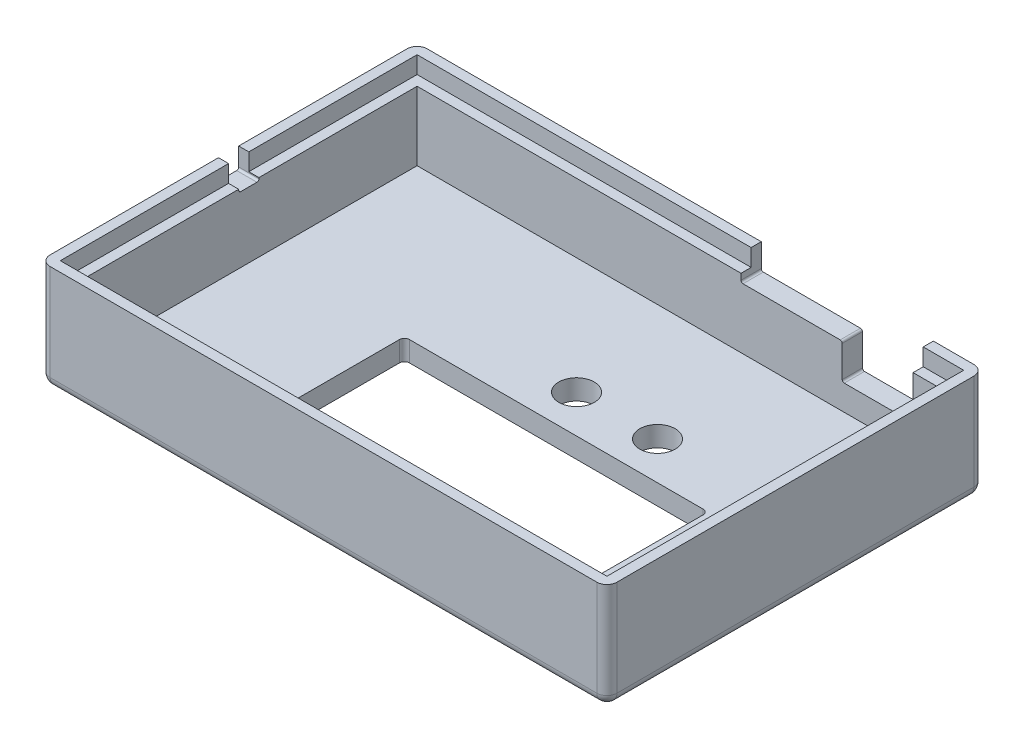
from build123d import *

# Parameters (mm, degrees)
SKETCH1_W           = 56
SKETCH1_H           = 37.25
BOSS_EXTRUDE1_DEPTH = 2
SKETCH2_W           = 56
SKETCH2_H           = 37.25
SKETCH2_W_2         = 52
SKETCH2_H_2         = 33.25
BOSS_EXTRUDE2_DEPTH = 8.5
SKETCH5_W           = 54
SKETCH5_H           = 35.25
SKETCH5_W_2         = 52
SKETCH5_H_2         = 33.25
CUT_EXTRUDE1_DEPTH  = 1
FILLET1_R           = 1
SKETCH7_W           = 30
SKETCH7_H           = 14
CUT_EXTRUDE3_DEPTH  = 10
SKETCH8_R           = 1.75
CUT_EXTRUDE4_DEPTH  = 10
SKETCH9_W           = 7
SKETCH9_H           = 6
CUT_EXTRUDE5_DEPTH  = 3
SKETCH10_W          = 10
SKETCH10_H          = 2.5
CUT_EXTRUDE6_DEPTH  = 3
FILLET2_R           = 0.5
FILLET3_R           = 1
FILLET5_R           = 0.2
CUT_EXTRUDE8_DEPTH  = 0.7
CUT_EXTRUDE10_DEPTH = 5
FILLET6_R           = 0.2


with BuildPart() as part:
    # Sketch1 → Boss-Extrude1 (new body)
    with BuildSketch(Plane(origin=(0, 0, 0), x_dir=(1, 0, 0), z_dir=(0, 1, 0))):
        with Locations((28, 18.625)):
            Rectangle(SKETCH1_W, SKETCH1_H)
    extrude(amount=BOSS_EXTRUDE1_DEPTH)

    # Sketch2 → Boss-Extrude2 (add)
    with BuildSketch(Plane(origin=(0, 2, 0), x_dir=(1, 0, 0), z_dir=(0, 1, 0))):
        with Locations((28, 18.625)):
            Rectangle(SKETCH2_W, SKETCH2_H)
        with Locations((28, 18.625)):
            Rectangle(SKETCH2_W_2, SKETCH2_H_2, mode=Mode.SUBTRACT)
    extrude(amount=BOSS_EXTRUDE2_DEPTH)

    # Sketch5 → Cut-Extrude1 (cut)
    with BuildSketch(Plane(origin=(0, 10.5, 0), x_dir=(1, 0, 0), z_dir=(0, 1, 0))):
        with Locations((28, 18.625)):
            Rectangle(SKETCH5_W, SKETCH5_H)
        with Locations((28, 18.625)):
            Rectangle(SKETCH5_W_2, SKETCH5_H_2, mode=Mode.SUBTRACT)
        with Locations((28, 18.625)):
            Rectangle(SKETCH5_W_2, SKETCH5_H_2)
    extrude(amount=-CUT_EXTRUDE1_DEPTH, mode=Mode.SUBTRACT)

    # Fillet1
    fillet1_edges = [part.edges().sort_by_distance(p)[0] for p in [
        (0, 5.25, -37.25),
        (56, 5.25, -37.25),
        (56, 5.25, 0),
        (0, 5.25, 0),
    ]]
    fillet(fillet1_edges, radius=FILLET1_R)

    # Sketch7 → Cut-Extrude3 (cut)
    with BuildSketch(Plane(origin=(0, 2, 0), x_dir=(1, 0, 0), z_dir=(0, 1, 0))):
        with Locations((31, 13)):
            Rectangle(SKETCH7_W, SKETCH7_H)
    extrude(amount=-CUT_EXTRUDE3_DEPTH, mode=Mode.SUBTRACT)

    # Sketch8 → Cut-Extrude4 (cut)
    with BuildSketch(Plane.XZ):
        with Locations((29.24999924, -23.74999914)):
            Circle(SKETCH8_R)
        with Locations((37.25000102, -23.74999914)):
            Circle(SKETCH8_R)
    extrude(amount=-CUT_EXTRUDE4_DEPTH, mode=Mode.SUBTRACT)

    # Sketch9 → Cut-Extrude5 (cut)
    with BuildSketch(Plane(origin=(0, 0, -37.25), x_dir=(-1, 0, 0), z_dir=(0, 0, -1))):
        with Locations((-47.5, 7.5)):
            Rectangle(SKETCH9_W, SKETCH9_H)
    extrude(amount=-CUT_EXTRUDE5_DEPTH, mode=Mode.SUBTRACT)

    # Sketch10 → Cut-Extrude6 (cut)
    with BuildSketch(Plane(origin=(0, 0, -37.25), x_dir=(-1, 0, 0), z_dir=(0, 0, -1))):
        with Locations((-39, 9.25)):
            Rectangle(SKETCH10_W, SKETCH10_H)
    extrude(amount=-CUT_EXTRUDE6_DEPTH, mode=Mode.SUBTRACT)

    # Fillet2
    fillet2_edges = [part.edges().sort_by_distance(p)[0] for p in [
        (16, 1, -6),
        (16, 1, -20),
        (46, 1, -20),
        (46, 1, -6),
    ]]
    fillet(fillet2_edges, radius=FILLET2_R)

    # Fillet3
    fillet3_edges = [part.edges().sort_by_distance(p)[0] for p in [
        (28, 0, -37.25),
        (0, 0, -18.625),
        (56, 0, -18.625),
        (28, 0, 0),
        (0.292893219, 0, -0.292893219),
        (0.292893219, 0, -36.957106781),
        (55.707106781, 0, -0.292893219),
        (55.707106781, 0, -36.957106781),
    ]]
    fillet(fillet3_edges, radius=FILLET3_R)

    # Fillet5
    fillet5_edges = [part.edges().sort_by_distance(p)[0] for p in [
        (51, 4.5, -36.25),
        (44, 4.5, -36.25),
        (44, 8, -36.25),
        (34, 8, -36.25),
    ]]
    fillet(fillet5_edges, radius=FILLET5_R)

    # Sketch12 → Cut-Extrude8 (cut)
    with BuildSketch(Plane(origin=(0, 9.5, 0), x_dir=(1, 0, 0), z_dir=(0, 1, 0))):
        Polygon((34, 35.25), (34, 36.25), (1, 36.25), (1, 1), (55, 1), (55, 36.25), (51, 36.25), (51, 35.25), (54, 35.25), (54, 2), (2, 2), (2, 35.25), align=None)
    extrude(amount=-CUT_EXTRUDE8_DEPTH, mode=Mode.SUBTRACT)

    # Sketch13 → Cut-Extrude10 (cut)
    with BuildSketch(Plane.ZY):
        Polygon((-18.625, 8.5), (-19.625, 8.5), (-19.625, 10.5), (-17.625, 10.5), (-17.625, 8.5), align=None)
    extrude(amount=-CUT_EXTRUDE10_DEPTH, mode=Mode.SUBTRACT)

    # Fillet6
    fillet6_edges = [part.edges().sort_by_distance(p)[0] for p in [
        (1, 8.5, -17.625),
        (1, 8.5, -19.625),
    ]]
    fillet(fillet6_edges, radius=FILLET6_R)


solid = part.part
